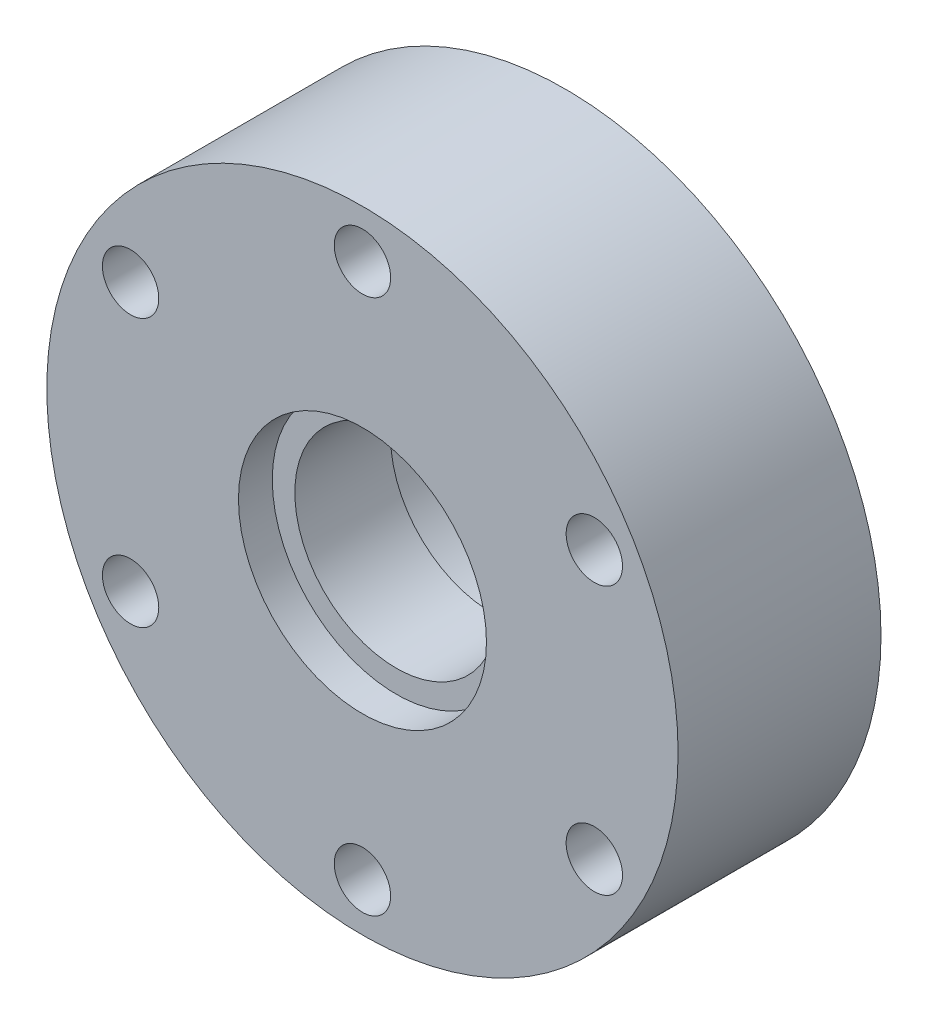
from build123d import *

# Parameters (mm, degrees)
SKETCH1_R                = 28
BOSS_EXTRUDE1_DEPTH      = 9
SKETCH2_R                = 11
CUT_EXTRUDE1_DEPTH       = 3
SKETCH3_R                = 9
CUT_EXTRUDE2_DEPTH       = 16
SKETCH4_R                = 11
CUT_EXTRUDE3_DEPTH       = 6.5
SKETCH_1_R               = 2.5
CUT_EXTRUDE_1_DEPTH      = 19
PATTERN_CIRCULAR_1_COUNT = 6


with BuildPart() as part:
    # Sketch1 → Boss-Extrude1 (new body, symmetric)
    with BuildSketch(Plane.XY):
        Circle(SKETCH1_R)
    extrude(amount=BOSS_EXTRUDE1_DEPTH, both=True)

    # Sketch2 → Cut-Extrude1 (cut)
    with BuildSketch(Plane.XY.offset(9)):
        Circle(SKETCH2_R)
    extrude(amount=-CUT_EXTRUDE1_DEPTH, mode=Mode.SUBTRACT)

    # Sketch3 → Cut-Extrude2 (cut, through all)
    with BuildSketch(Plane.XY.offset(6)):
        Circle(SKETCH3_R)
    extrude(amount=-CUT_EXTRUDE2_DEPTH, mode=Mode.SUBTRACT)

    # Sketch4 → Cut-Extrude3 (cut)
    with BuildSketch(Plane(origin=(0, 0, -9), x_dir=(-1, 0, 0), z_dir=(0, 0, -1))):
        Circle(SKETCH4_R)
    extrude(amount=-CUT_EXTRUDE3_DEPTH, mode=Mode.SUBTRACT)

    # 草圖1 → 除料-伸長1 (cut, through all)
    with BuildSketch(Plane.XY.offset(9)):
        with Locations((0, 23.75)):
            Circle(SKETCH_1_R)
    cut_extrude_1 = extrude(amount=-CUT_EXTRUDE_1_DEPTH, mode=Mode.SUBTRACT)

    # 環狀複製排列1: 除料-伸長1 ×6 about axis
    pattern_circular_1_axis = Axis((0, 0, 0), (0, 0, 1))
    for i in range(1, PATTERN_CIRCULAR_1_COUNT):
        add(cut_extrude_1.rotate(pattern_circular_1_axis, i * 360 / PATTERN_CIRCULAR_1_COUNT), mode=Mode.SUBTRACT)


solid = part.part
